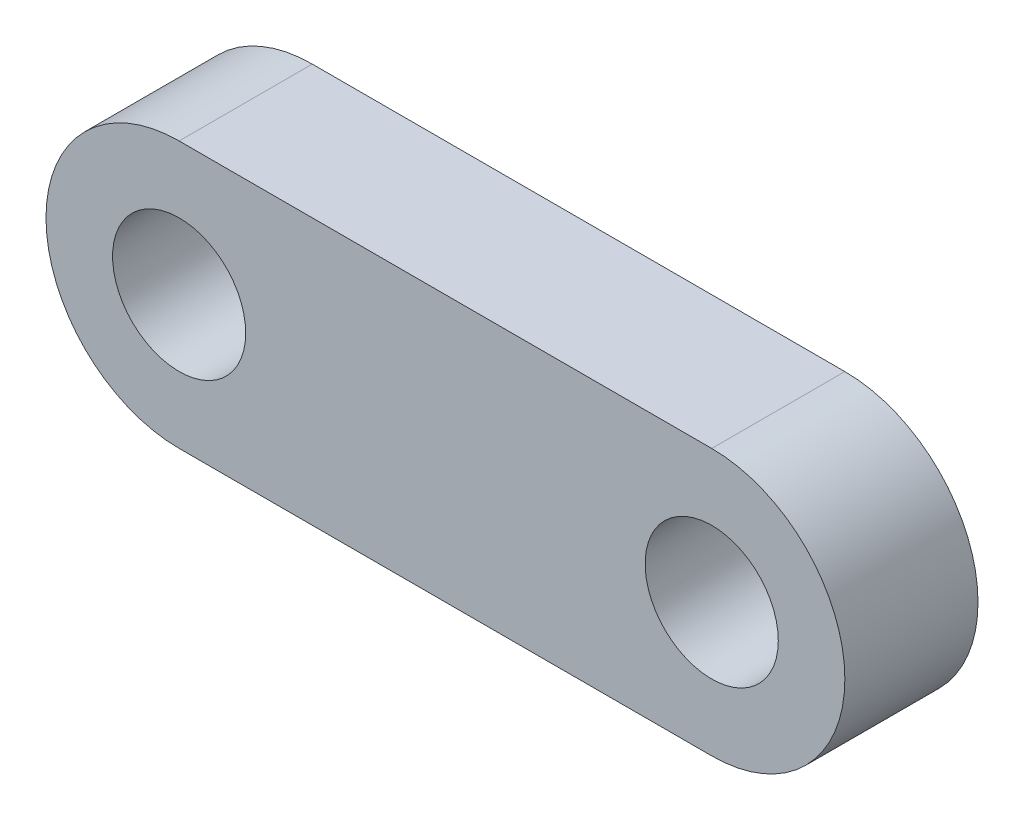
from build123d import *

# Parameters (mm, degrees)
BASE_EXTRUDE_DEPTH              = 3.175
F_1_4_0_250000_DIAMETER_HOLE1_D = 6.35


with BuildPart() as part:
    # profile → Base-Extrude (new body, symmetric)
    with BuildSketch(Plane.XY):
        with BuildLine():
            Line((-25.4, 6.35), (0, 6.35))
            ThreePointArc((0, 6.35), (6.35, 0), (0, -6.35))
            Line((0, -6.35), (-25.4, -6.35))
            ThreePointArc((-25.4, -6.35), (-31.75, 0), (-25.4, 6.35))
        make_face()
    extrude(amount=BASE_EXTRUDE_DEPTH, both=True)

    # 1/4 (0.250000) Diameter Hole1 (through all)
    with Locations(Plane.XY.offset(3.175)):
        with Locations((-25.4, 0), (0, 0)):
            Hole(F_1_4_0_250000_DIAMETER_HOLE1_D / 2)


solid = part.part
